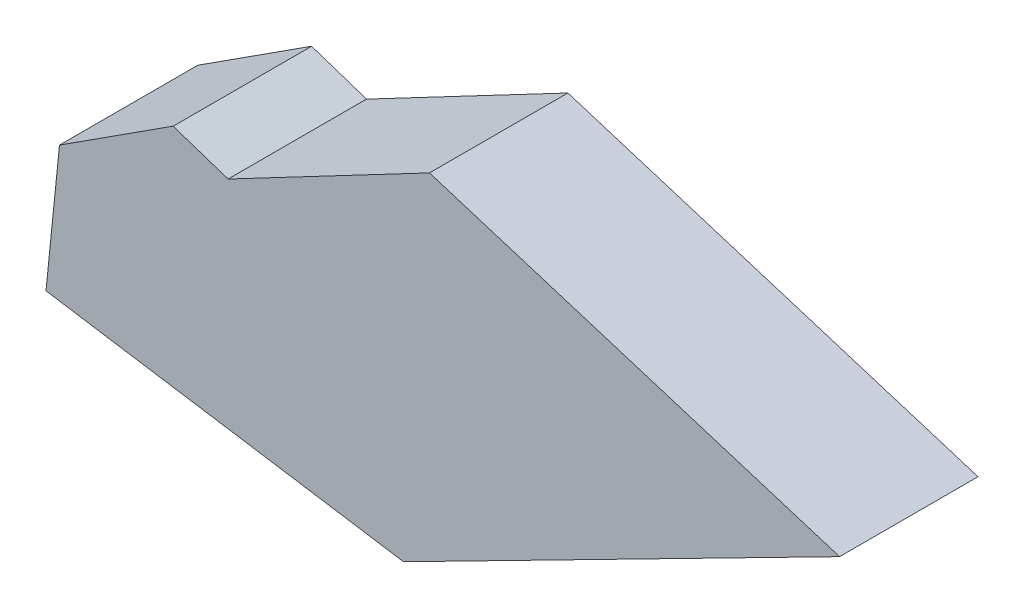
from build123d import *

# Parameters (mm, degrees)
BOSS_EXTRUDE1_DEPTH = 40


with BuildPart() as part:
    # Sketch1 → Boss-Extrude1 (new body)
    with BuildSketch(Plane.XY):
        Polygon((-41.210825625, 11.416512504), (16.985542994, 42.046180199), (135.510759858, 5.262492206), (9.467351833, -59.031723193), (-93.838163755, -42.881534772), (-89.939842412, -4.455224392), (-57.082562521, 16.70709147), align=None)
    extrude(amount=BOSS_EXTRUDE1_DEPTH)


solid = part.part
